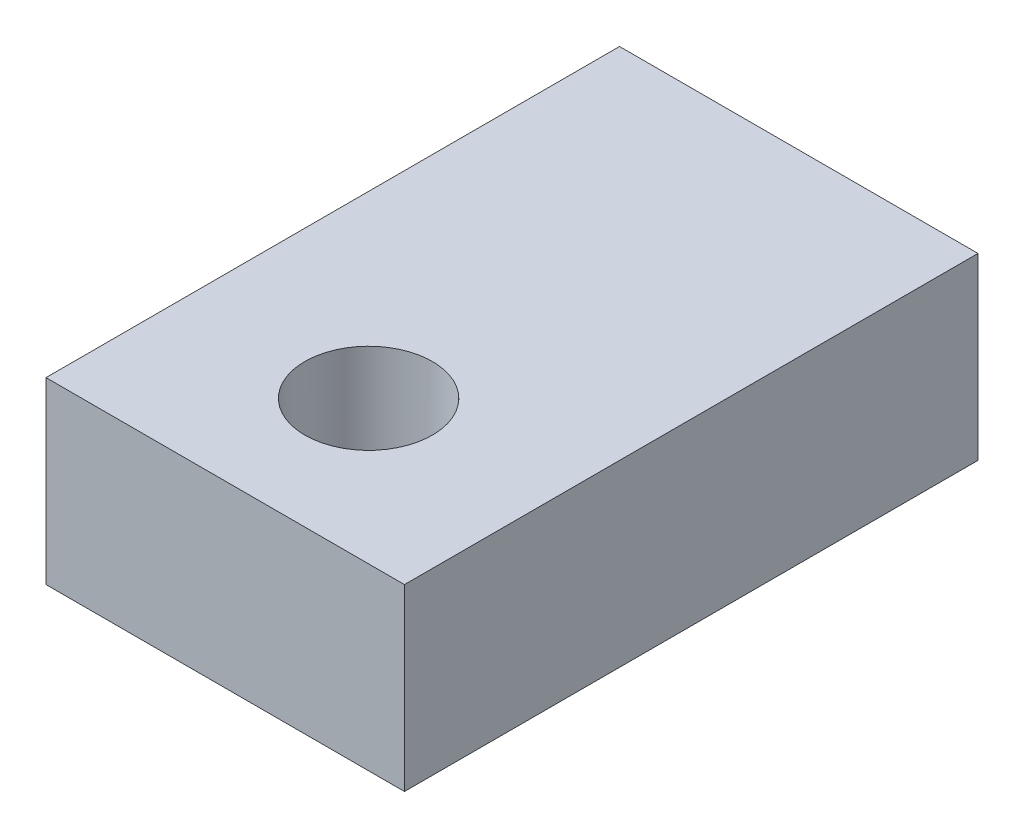
from build123d import *

# Parameters (mm, degrees)
SKETCH1_W                 = 6.35
SKETCH1_H                 = 10.16
BOSS_EXTRUDE1_DEPTH       = 3.175
F_4_40_TAPPED_HOLE1_D     = 2.2606
F_4_40_TAPPED_HOLE1_DEPTH = 7.5946
F_4_40_TAPPED_HOLE1_TIP   = 0.679152758


with BuildPart() as part:
    # Sketch1 → Boss-Extrude1 (new body)
    with BuildSketch(Plane(origin=(0, 0, 0), x_dir=(1, 0, 0), z_dir=(0, 1, 0))):
        Rectangle(SKETCH1_W, SKETCH1_H)
    extrude(amount=BOSS_EXTRUDE1_DEPTH)

    # #4-40 Tapped Hole1
    with Locations(Plane(origin=(0, 3.175, 0), x_dir=(1, 0, 0), z_dir=(0, 1, 0))):
        with Locations((0, -2.54)):
            Hole(F_4_40_TAPPED_HOLE1_D / 2, depth=F_4_40_TAPPED_HOLE1_DEPTH)
            with Locations((0, 0, -(F_4_40_TAPPED_HOLE1_DEPTH + F_4_40_TAPPED_HOLE1_TIP / 2))):  # 118° drill point
                Cone(0, F_4_40_TAPPED_HOLE1_D / 2, F_4_40_TAPPED_HOLE1_TIP, mode=Mode.SUBTRACT)


solid = part.part
